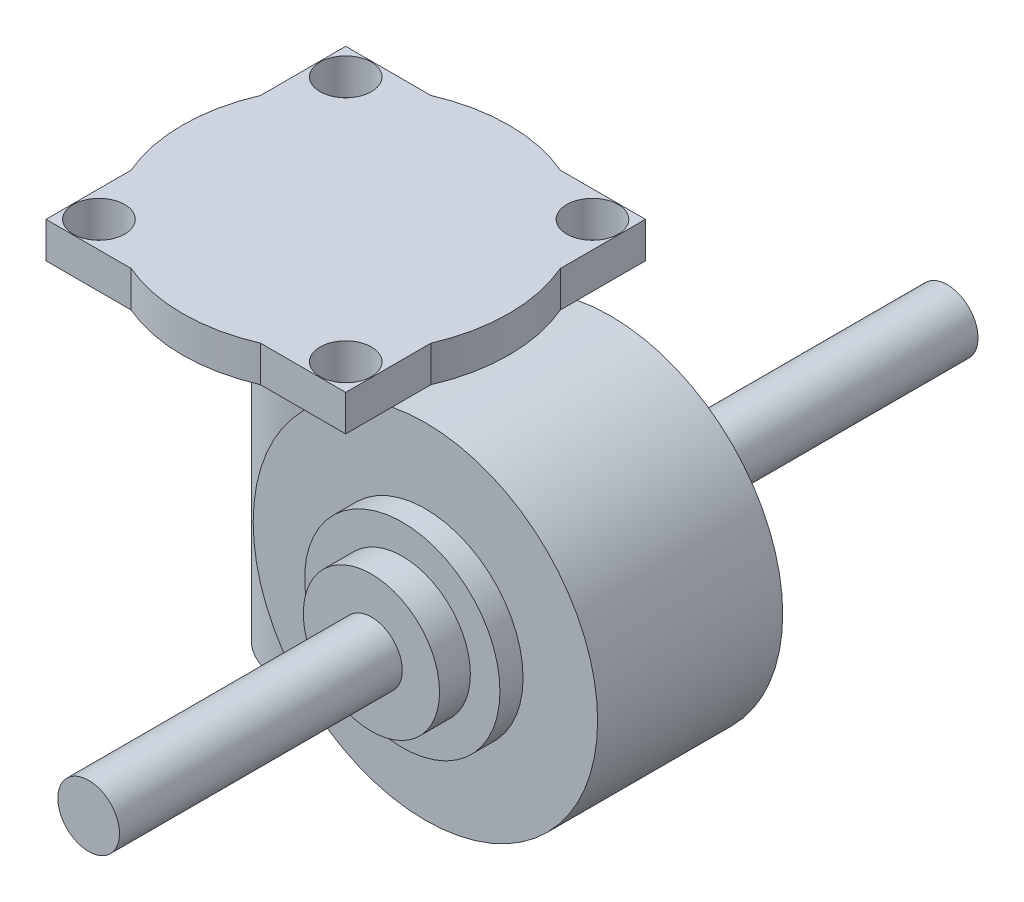
from build123d import *

# Parameters (mm, degrees)
SKIZZE1_R                            = 33.5
AUFSATZ_LINEAR_AUSTRAGEN1_DEPTH      = 36
SKIZZE2_R                            = 19
AUFSATZ_LINEAR_AUSTRAGEN2_DEPTH      = 4.5
SKIZZE3_R                            = 13.25
AUFSATZ_LINEAR_AUSTRAGEN3_DEPTH      = 6
SKIZZE4_R                            = 13
AUFSATZ_LINEAR_AUSTRAGEN4_DEPTH      = 26
AUFSATZ_LINEAR_AUSTRAGEN4_DEPTH_BACK = 29
SKIZZE5_R                            = 20
AUFSATZ_LINEAR_AUSTRAGEN5_DEPTH      = 9
SKIZZE6_R                            = 31.75
AUFSATZ_LINEAR_AUSTRAGEN6_DEPTH      = 7
SKIZZE7_W                            = 58.3
SKIZZE7_H                            = 58.3
AUFSATZ_LINEAR_AUSTRAGEN7_DEPTH      = 7
F_10_0_10_DURCHMESSER_BOHRUNG1_D     = 10
F_10_0_10_DURCHMESSER_BOHRUNG1_DEPTH = 7
SKIZZE13_R                           = 19
AUFSATZ_LINEAR_AUSTRAGEN8_DEPTH      = 4.5
SKIZZE14_R                           = 13.25
AUFSATZ_LINEAR_AUSTRAGEN9_DEPTH      = 6
SKIZZE15_R                           = 6
AUFSATZ_LINEAR_AUSTRAGEN10_DEPTH     = 55
SKIZZE16_R                           = 6
AUFSATZ_LINEAR_AUSTRAGEN11_DEPTH     = 55


with BuildPart() as part:
    # Skizze1 → Aufsatz-Linear austragen1 (new body)
    with BuildSketch(Plane.XY):
        Circle(SKIZZE1_R)
    extrude(amount=AUFSATZ_LINEAR_AUSTRAGEN1_DEPTH)

    # Skizze2 → Aufsatz-Linear austragen2 (add)
    with BuildSketch(Plane.XY.offset(36)):
        Circle(SKIZZE2_R)
    extrude(amount=AUFSATZ_LINEAR_AUSTRAGEN2_DEPTH)

    # Skizze3 → Aufsatz-Linear austragen3 (add)
    with BuildSketch(Plane.XY.offset(40.5)):
        Circle(SKIZZE3_R)
    extrude(amount=AUFSATZ_LINEAR_AUSTRAGEN3_DEPTH)

    # Skizze4 → Aufsatz-Linear austragen4 (add, two sides)
    with BuildSketch(Plane(origin=(0, 0, 0), x_dir=(1, 0, 0), z_dir=(0, 1, 0))) as aufsatz_linear_austragen4_sk:
        with Locations((-33.5, -18)):
            Circle(SKIZZE4_R)
    extrude(amount=AUFSATZ_LINEAR_AUSTRAGEN4_DEPTH)
    extrude(aufsatz_linear_austragen4_sk.sketch, amount=-AUFSATZ_LINEAR_AUSTRAGEN4_DEPTH_BACK)

    # Skizze5 → Aufsatz-Linear austragen5 (add)
    with BuildSketch(Plane(origin=(0, 26, 0), x_dir=(1, 0, 0), z_dir=(0, 1, 0))):
        with Locations((-33.5, -18)):
            Circle(SKIZZE5_R)
    extrude(amount=AUFSATZ_LINEAR_AUSTRAGEN5_DEPTH)

    # Skizze6 → Aufsatz-Linear austragen6 (add)
    with BuildSketch(Plane(origin=(0, 35, 0), x_dir=(1, 0, 0), z_dir=(0, 1, 0))):
        with Locations((-33.5, -18)):
            Circle(SKIZZE6_R)
    extrude(amount=AUFSATZ_LINEAR_AUSTRAGEN6_DEPTH)

    # Skizze7 → Aufsatz-Linear austragen7 (add)
    with BuildSketch(Plane(origin=(0, 42, 0), x_dir=(1, 0, 0), z_dir=(0, 1, 0))):
        with Locations((-33.5, -18)):
            Rectangle(SKIZZE7_W, SKIZZE7_H)
    extrude(amount=-AUFSATZ_LINEAR_AUSTRAGEN7_DEPTH)

    # Ø10.0 (10) Durchmesser Bohrung1
    with Locations(Plane(origin=(0, 42, 0), x_dir=(1, 0, 0), z_dir=(0, 1, 0))):
        with Locations((-57.5, -42), (-57.5, 6), (-9.5, 6), (-9.5, -42)):
            Hole(F_10_0_10_DURCHMESSER_BOHRUNG1_D / 2, depth=F_10_0_10_DURCHMESSER_BOHRUNG1_DEPTH)

    # Skizze13 → Aufsatz-Linear austragen8 (add)
    with BuildSketch(Plane(origin=(0, 0, 0), x_dir=(-1, 0, 0), z_dir=(0, 0, -1))):
        Circle(SKIZZE13_R)
    extrude(amount=AUFSATZ_LINEAR_AUSTRAGEN8_DEPTH)

    # Skizze14 → Aufsatz-Linear austragen9 (add)
    with BuildSketch(Plane(origin=(0, 0, -4.5), x_dir=(-1, 0, 0), z_dir=(0, 0, -1))):
        Circle(SKIZZE14_R)
    extrude(amount=AUFSATZ_LINEAR_AUSTRAGEN9_DEPTH)

    # Skizze15 → Aufsatz-Linear austragen10 (add)
    with BuildSketch(Plane(origin=(0, 0, -10.5), x_dir=(-1, 0, 0), z_dir=(0, 0, -1))):
        Circle(SKIZZE15_R)
    extrude(amount=AUFSATZ_LINEAR_AUSTRAGEN10_DEPTH)

    # Skizze16 → Aufsatz-Linear austragen11 (add)
    with BuildSketch(Plane.XY.offset(46.5)):
        Circle(SKIZZE16_R)
    extrude(amount=AUFSATZ_LINEAR_AUSTRAGEN11_DEPTH)


solid = part.part
